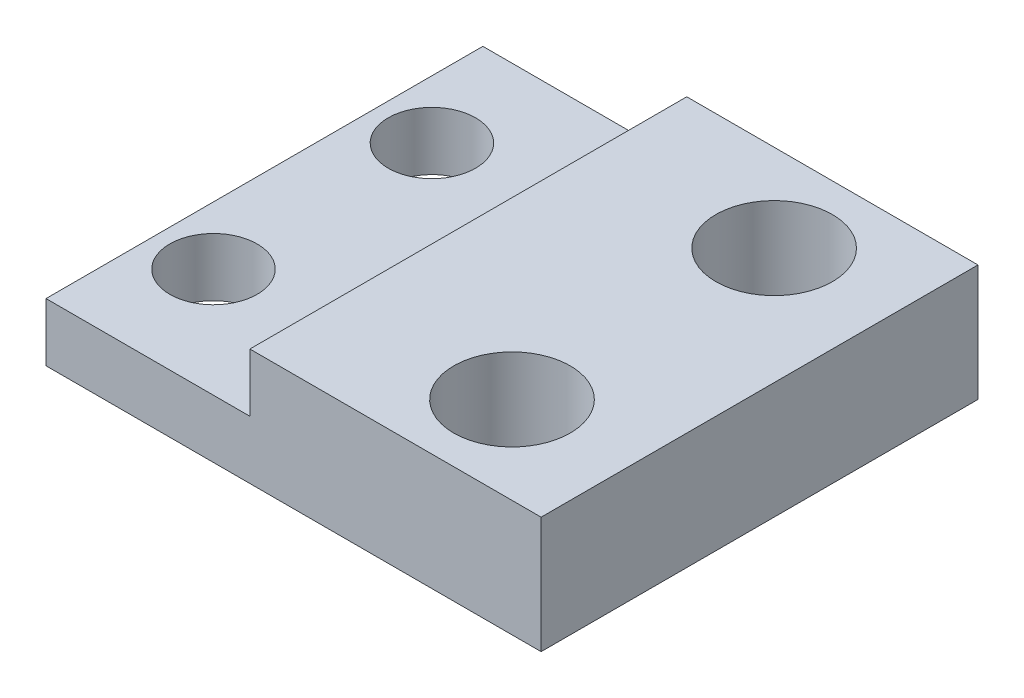
from build123d import *

# Parameters (mm, degrees)
CROQUIS1_W              = 20
CROQUIS1_H              = 15
CROQUIS1_R              = 1.5
CROQUIS1_R_2            = 2
SALIENTE_EXTRUIR1_DEPTH = 4
CORTAR_EXTRUIR1_DEPTH   = 16


with BuildPart() as part:
    # Croquis1 → Saliente-Extruir1 (new body)
    with BuildSketch(Plane(origin=(0, 0, 0), x_dir=(1, 0, 0), z_dir=(0, 1, 0))):
        Rectangle(CROQUIS1_W, CROQUIS1_H)
        with Locations((-5, 3.75)):
            Circle(CROQUIS1_R, mode=Mode.SUBTRACT)
        with Locations((-5, -3.75)):
            Circle(CROQUIS1_R, mode=Mode.SUBTRACT)
        with Locations((6, 4.5)):
            Circle(CROQUIS1_R_2, mode=Mode.SUBTRACT)
        with Locations((6, -4.5)):
            Circle(CROQUIS1_R_2, mode=Mode.SUBTRACT)
    extrude(amount=SALIENTE_EXTRUIR1_DEPTH)

    # Croquis2 → Cortar-Extruir1 (cut, through all)
    with BuildSketch(Plane(origin=(0, -3.5, 7.5), x_dir=(1, 0, 0), z_dir=(0, 0, -1))):
        Polygon((-10, -7.5), (0, -7.5), (0, -5.5), (-7, -5.5), (-7, -3.5), (-10, -3.5), align=None)
    extrude(amount=CORTAR_EXTRUIR1_DEPTH, mode=Mode.SUBTRACT)


solid = part.part
